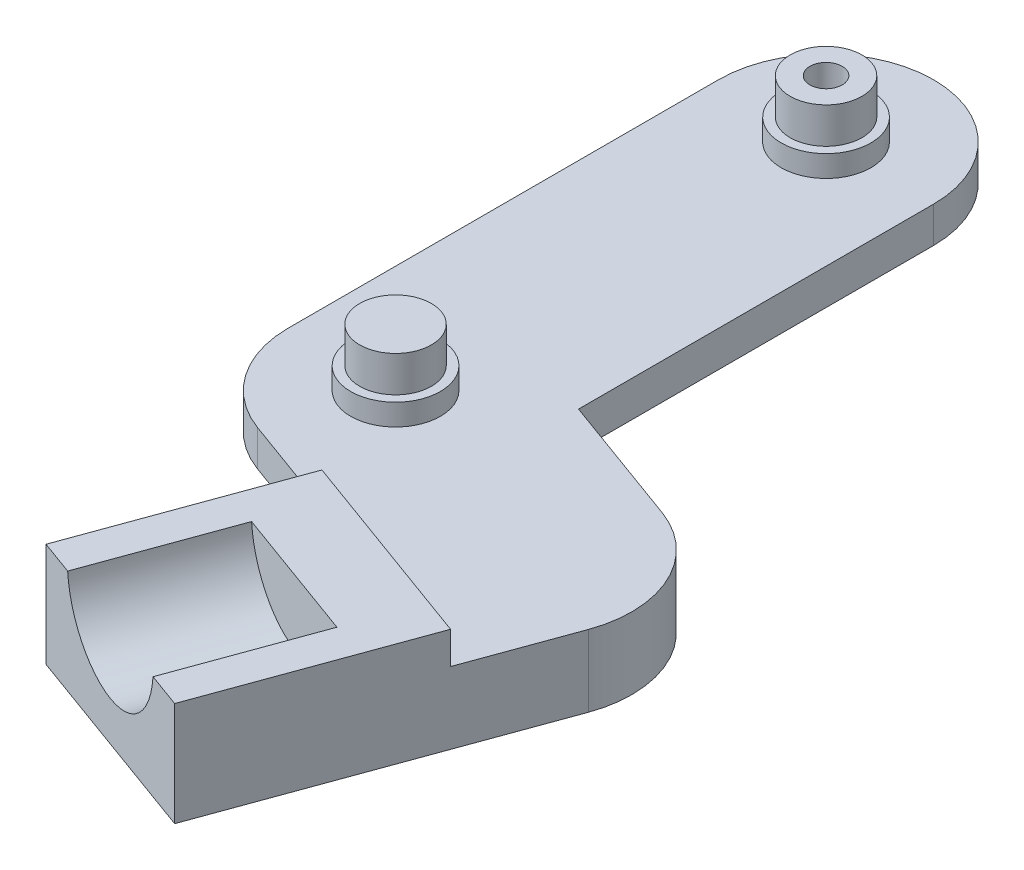
from build123d import *
from build123d.topology import SkipClean

# Parameters (mm, degrees)
EXTRUDE_1_DEPTH              = 5
SKETCH_2_R                   = 6.25
EXTRUDE_2_DEPTH              = 3
SKETCH_3_R                   = 5
EXTRUDE_3_DEPTH              = 5
HOLE_WIZARD_M4_1_D           = 4.5
HOLE_WIZARD_M4_1_CBORE_D     = 9
HOLE_WIZARD_M4_1_CBORE_DEPTH = 4
EXTRUDE_4_DEPTH              = 5
EXTRUDE_5_DEPTH              = 5
EXTRUDE_5_DEPTH_BACK         = 5
EXTRUDE_6_DEPTH              = 4.5
SKETCH_15_R                  = 10
CUT_EXTRUDE_2_DEPTH          = 20


with BuildPart() as part:
    # 스케치1 → 보스-돌출1 (new body)
    with BuildSketch(Plane(origin=(0, 0, 0), x_dir=(1, 0, 0), z_dir=(0, 1, 0))):
        with BuildLine():
            Line((-15, 0), (-15, 60))
            ThreePointArc((-15, 60), (0, 75), (15, 60))
            Line((15, 60), (15, 0))
            ThreePointArc((15, 0), (0, -15), (-15, 0))
        make_face()
    extrude(amount=EXTRUDE_1_DEPTH)

    # 스케치2 → 보스-돌출2 (add)
    with BuildSketch(Plane(origin=(0, 5, 0), x_dir=(1, 0, 0), z_dir=(0, 1, 0))):
        with Locations((0, 60)):
            Circle(SKETCH_2_R)
        Circle(SKETCH_2_R)
    extrude(amount=EXTRUDE_2_DEPTH)

    # 스케치3 → 보스-돌출3 (add)
    with BuildSketch(Plane(origin=(0, 8, 0), x_dir=(1, 0, 0), z_dir=(0, 1, 0))):
        with Locations((0, 60)):
            Circle(SKETCH_3_R)
        Circle(SKETCH_3_R)
    extrude(amount=EXTRUDE_3_DEPTH)

    # M4 남비 머리 나사용 카운터보어1 (through all)
    with Locations(Plane(origin=(0, 0, 0), x_dir=(-1, 0, 0), z_dir=(0, -1, 0))):
        with Locations((0, 60), (0, -25)):
            CounterBoreHole(HOLE_WIZARD_M4_1_D / 2, HOLE_WIZARD_M4_1_CBORE_D / 2, HOLE_WIZARD_M4_1_CBORE_DEPTH)

    # 스케치8 → 보스-돌출4 (add)
    with BuildSketch(Plane.XZ):
        with BuildLine():
            Line((-5.13030215, 14.095389312), (23.060476474, 24.355993612))
            ThreePointArc((23.060476474, 24.355993612), (42.286167935, 15.39090645), (33.321080773, -3.834785012))
            Line((33.321080773, -3.834785012), (15, -10.503113073))
            Line((15, -10.503113073), (15, 0))
            ThreePointArc((15, 0), (8.603646545, 12.287280664), (-5.13030215, 14.095389312))
        make_face()
    extrude(amount=-EXTRUDE_4_DEPTH)

    # 스케치9 → 보스-돌출5 (add, two sides: drawn at the far end of the back side and taken through both)
    with SkipClean():  # the faces are left unmerged after this step: merging them gives an invalid solid
        with BuildSketch(Plane.XZ.offset(-EXTRUDE_5_DEPTH_BACK)):
            with BuildLine():
                Line((14.095389312, 5.13030215), (3.834785012, 33.321080773))
                Line((3.834785012, 33.321080773), (-1.295517138, 47.416470085))
                Line((-1.295517138, 47.416470085), (26.895261486, 57.677074385))
                Line((26.895261486, 57.677074385), (32.025563636, 43.581685073))
                Line((32.025563636, 43.581685073), (42.286167935, 15.39090645))
                ThreePointArc((42.286167935, 15.39090645), (33.321080773, -3.834785012), (14.095389312, 5.13030215))
            make_face()
        extrude(amount=EXTRUDE_5_DEPTH + EXTRUDE_5_DEPTH_BACK)

    # 스케치13 → 보스-돌출6 (add)
    with SkipClean():  # the faces are left unmerged after this step: merging them gives an invalid solid
        with BuildSketch(Plane(origin=(0, 5, 0), x_dir=(1, 0, 0), z_dir=(0, 1, 0))):
            Polygon((37.155865785, -29.486295761), (26.895261486, -57.677074385), (-1.295517138, -47.416470085), (8.965087162, -19.225691462), align=None)
        extrude(amount=EXTRUDE_6_DEPTH)

    # 스케치15 → 컷-돌출2 (cut)
    with SkipClean():  # the faces are left unmerged after this step: merging them gives an invalid solid
        with BuildSketch(Plane(origin=(-15.39090645, 0, 42.286167935), x_dir=(0.9396926207859084, 0, 0.3420201433256689), z_dir=(-0.3420201433256689, 0, 0.9396926207859084))):
            with Locations((30, 10.5)):
                Circle(SKETCH_15_R)
        extrude(amount=-CUT_EXTRUDE_2_DEPTH, mode=Mode.SUBTRACT)


solid = part.part
